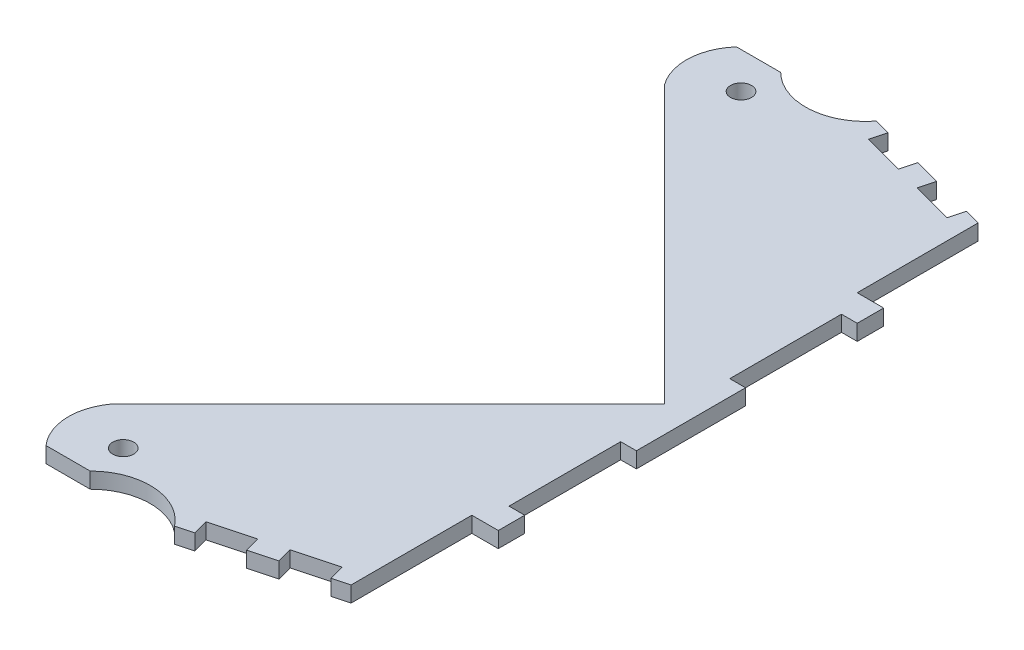
from build123d import *

# Parameters (mm, degrees)
SKETCH1_R           = 3.175
BOSS_EXTRUDE1_DEPTH = 4.7625
SKETCH2_W           = 4.7625
SKETCH2_H           = 33.783
CUT_EXTRUDE1_DEPTH  = 5


with BuildPart() as part:
    # Sketch1 → Boss-Extrude1 (new body)
    with BuildSketch(Plane(origin=(0, 0, 0), x_dir=(1, 0, 0), z_dir=(0, 1, 0))):
        with BuildLine():
            Line((-82.674132744, 104.451069294), (-69.310188895, 104.451069294))
            ThreePointArc((-69.310188895, 104.451069294), (-55.336180049, 99.157726681), (-42.113057451, 106.117714323))
            Line((-42.113057451, 106.117714323), (0, 94.833554589))
            Line((0, 94.833554589), (0, 58.293))
            Line((0, 58.293), (8, 58.293))
            Line((8, 58.293), (8, -58.293))
            Line((8, -58.293), (0, -58.293))
            Line((0, -58.293), (0, -94.833554589))
            Line((0, -94.833554589), (-42.113057451, -106.117714323))
            ThreePointArc((-42.113057451, -106.117714323), (-55.336180049, -99.157726681), (-69.310188895, -104.451069294))
            Line((-69.310188895, -104.451069294), (-82.674132744, -104.451069294))
            ThreePointArc((-82.674132744, -104.451069294), (-86.841727728, -94.209575285), (-83.629476528, -83.629476528))
            Line((-83.629476528, -83.629476528), (0, 0))
            Line((0, 0), (-83.629476528, 83.629476528))
            ThreePointArc((-83.629476528, 83.629476528), (-86.841727728, 94.209575285), (-82.674132744, 104.451069294))
        make_face()
        with Locations((-70.310188895, 93.451069294)):
            Circle(SKETCH1_R, mode=Mode.SUBTRACT)
        with Locations((-70.310188895, -93.451069294)):
            Circle(SKETCH1_R, mode=Mode.SUBTRACT)
    extrude(amount=BOSS_EXTRUDE1_DEPTH)

    # Sketch2 → Cut-Extrude1 (cut)
    with BuildSketch(Plane(origin=(0, 0, 0), x_dir=(1, 0, 0), z_dir=(0, 1, 0))):
        Polygon((-17.19282542, -99.440358276), (-4.829629131, -96.127649814), (-6.062254834, -91.527428067), (-18.425451123, -94.840136528), align=None)
        Polygon((-37.283428319, -104.823619098), (-24.920232031, -101.510910637), (-26.152857733, -96.910688889), (-38.516054022, -100.22339735), align=None)
        with Locations((5.61875, -33.4015)):
            Rectangle(SKETCH2_W, SKETCH2_H)
        Polygon((-38.516054022, 100.22339735), (-26.152857733, 96.910688889), (-24.920232031, 101.510910637), (-37.283428319, 104.823619098), align=None)
        Polygon((-18.425451123, 94.840136528), (-6.062254834, 91.527428067), (-4.829629131, 96.127649814), (-17.19282542, 99.440358276), align=None)
        with Locations((5.61875, 33.4015)):
            Rectangle(SKETCH2_W, SKETCH2_H)
    extrude(amount=CUT_EXTRUDE1_DEPTH, mode=Mode.SUBTRACT)


solid = part.part
